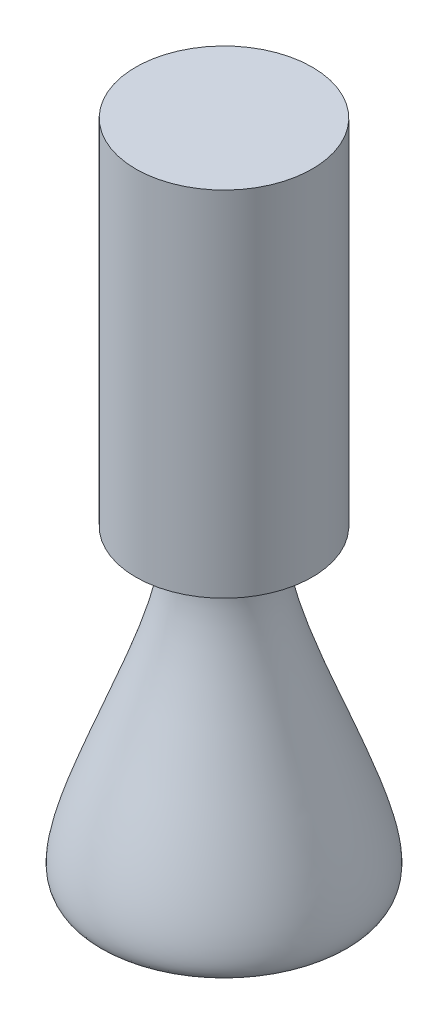
from build123d import *


with BuildPart() as part:
    # Sketch1 → Revolve1 (revolve)
    with BuildSketch(Plane.XY):
        with BuildLine():
            Line((0, 0), (17, 0))
            add(Edge.make_bspline(
                [(17, 0), (21.06784347, 5.586104345), (-4.644607655, 47.447667598), (12.235109489, 42.215835752)],
                knots=[0, 0, 0, 0, 1, 1, 1, 1], degree=3))
            Line((12.235109489, 42.215835752), (12.235109489, 91.215835752))
            Line((12.235109489, 91.215835752), (0, 91.215835752))
            Line((0, 91.215835752), (0, 0))
        make_face()
    revolve(axis=Axis((0, 0, 0), (0, 1, 0)))


solid = part.part
